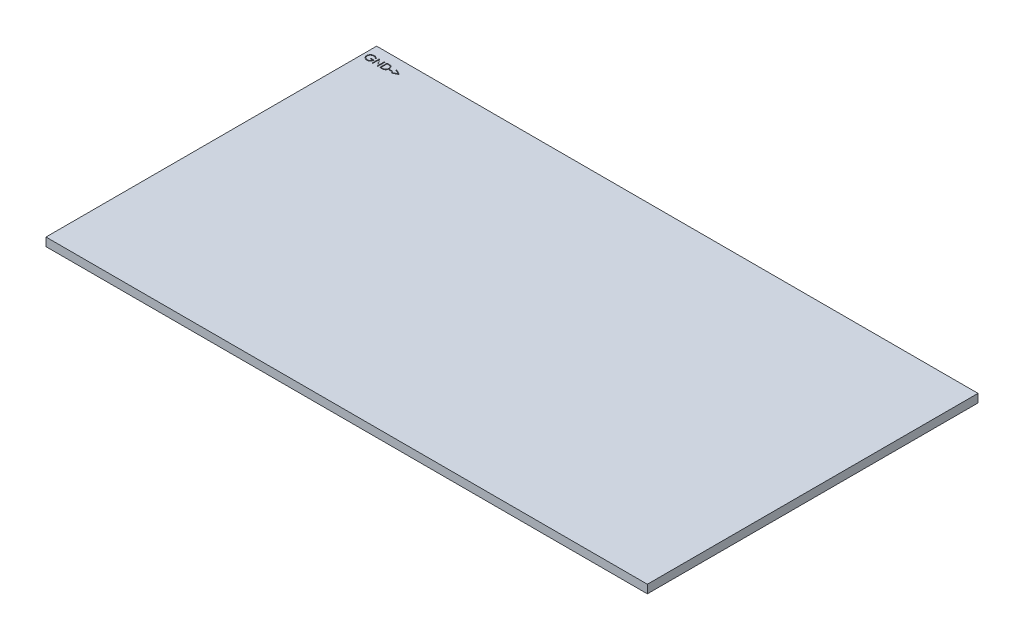
from build123d import *

# Parameters (mm, degrees)
SKETCH1_W           = 114.2
SKETCH1_H           = 62.784
BOSS_EXTRUDE1_DEPTH = 1.5875
SKETCH2_W           = 0.538461539
SKETCH2_H           = 0.143589744
CUT_EXTRUDE1_DEPTH  = 0.2
SKETCH5_W           = 0.538461539
SKETCH5_H           = 0.143589743
CUT_EXTRUDE2_DEPTH  = 0.2


with BuildPart() as part:
    # Sketch1 → Boss-Extrude1 (new body)
    with BuildSketch(Plane(origin=(0, 0, 0), x_dir=(1, 0, 0), z_dir=(0, 1, 0))):
        with Locations((57.1, 18.392)):
            Rectangle(SKETCH1_W, SKETCH1_H)
    extrude(amount=BOSS_EXTRUDE1_DEPTH)

    # Sketch2 → Cut-Extrude1 (cut)
    with BuildSketch(Plane(origin=(0, 1.5875, 0), x_dir=(1, 0, 0), z_dir=(0, 1, 0))):
        with BuildLine():
            Line((1.979573781, 47.737471022), (1.871881473, 47.635387688))
            add(Edge.make_bspline(
                [(1.871881473, 47.635387688), (1.852393918, 47.653720034), (1.813883499, 47.689947579), (1.751099402, 47.736951977), (1.685593949, 47.777218417), (1.61770895, 47.809980911), (1.549125528, 47.836122016), (1.480754018, 47.854733272), (1.413295737, 47.866602287), (1.36842885, 47.868021634), (1.346320576, 47.868721022)],
                knots=[0, 0, 0, 0, 8.0214e-05, 0.000158516, 0.0002348, 0.000310559, 0.000384315, 0.000454662, 0.000522898, 0.000589184, 0.000589184, 0.000589184, 0.000589184], degree=3))
            add(Edge.make_bspline(
                [(1.346320576, 47.868721022), (1.332754696, 47.868555579), (1.30565812, 47.868225124), (1.265409342, 47.864007438), (1.225582687, 47.857941492), (1.186253337, 47.849164741), (1.147344823, 47.838041117), (1.108992466, 47.824126932), (1.071124724, 47.807904834), (1.034098292, 47.789159845), (0.99820209, 47.768567906), (0.964299356, 47.74574849), (0.932173996, 47.721432974), (0.902429826, 47.695012582), (0.874895752, 47.666726636), (0.848916403, 47.637101313), (0.825405484, 47.605327226), (0.804169018, 47.571988976), (0.785224371, 47.5376721), (0.76850091, 47.502706904), (0.754462074, 47.467209362), (0.743354292, 47.431134931), (0.734190031, 47.394762695), (0.727742988, 47.357840807), (0.724108299, 47.320329733), (0.723479587, 47.29521083), (0.723163525, 47.282583201)],
                knots=[0, 0, 0, 0, 4.0681e-05, 8.1256e-05, 0.000121277, 0.000161491, 0.000202055, 0.000242597, 0.000283803, 0.000325569, 0.000367033, 0.000407869, 0.000448087, 0.00048782, 0.000527087, 0.000566449, 0.000605937, 0.000645536, 0.000684952, 0.000723463, 0.000761741, 0.00079935, 0.000836625, 0.000874202, 0.000911679, 0.000949566, 0.000949566, 0.000949566, 0.000949566], degree=3))
            add(Edge.make_bspline(
                [(0.723163525, 47.282583201), (0.723465812, 47.269674874), (0.724069561, 47.243893469), (0.727933689, 47.20541584), (0.735104985, 47.167509679), (0.744692069, 47.130050426), (0.756684395, 47.092973926), (0.771633461, 47.056440922), (0.789339702, 47.020452766), (0.809834322, 46.985333719), (0.832308804, 46.95112451), (0.857486036, 46.918900701), (0.88423027, 46.88823319), (0.913515829, 46.859802885), (0.944403646, 46.832849326), (0.977816557, 46.808115117), (1.013097541, 46.785123828), (1.050300426, 46.76416522), (1.089021539, 46.745441806), (1.12872424, 46.728792248), (1.169535366, 46.715080513), (1.211240442, 46.703905271), (1.253789751, 46.694745152), (1.297399272, 46.68885216), (1.341748355, 46.684575828), (1.371643808, 46.68426316), (1.386705191, 46.684105637)],
                knots=[0, 0, 0, 0, 3.8727e-05, 7.7349e-05, 0.000115853, 0.000154352, 0.000193286, 0.000232658, 0.000272668, 0.000313507, 0.000354576, 0.000395358, 0.000436093, 0.000476549, 0.000517706, 0.000558989, 0.000601149, 0.000643971, 0.000686993, 0.000730117, 0.000773042, 0.000816037, 0.0008596, 0.000903505, 0.00094799, 0.000993156, 0.000993156, 0.000993156, 0.000993156], degree=3))
            add(Edge.make_bspline(
                [(1.386705191, 46.684105637), (1.40485653, 46.684485068), (1.440499633, 46.685230141), (1.49289421, 46.691030257), (1.543215438, 46.700088974), (1.59132192, 46.713355333), (1.637269528, 46.730276803), (1.681226705, 46.750674958), (1.722847368, 46.775332181), (1.762256637, 46.803161728), (1.798559512, 46.834167661), (1.831301161, 46.867625443), (1.859959357, 46.90337267), (1.884961237, 46.941198796), (1.905644698, 46.981416918), (1.922621816, 47.023829943), (1.935635133, 47.068456948), (1.940977123, 47.0992936), (1.943676345, 47.114874868)],
                knots=[0, 0, 0, 0, 5.4442e-05, 0.000106907, 0.000157953, 0.000207688, 0.0002564, 0.000304703, 0.00035285, 0.000401328, 0.000449269, 0.000495875, 0.000541557, 0.000586516, 0.000631672, 0.00067698, 0.0007234, 0.000770811, 0.000770811, 0.000770811, 0.000770811], degree=3))
            Line((1.943676345, 47.114874868), (1.477009678, 47.114874868))
            Line((1.477009678, 47.114874868), (1.477009678, 47.258464611))
            Line((1.477009678, 47.258464611), (2.069317371, 47.258464611))
            add(Edge.make_bspline(
                [(2.069317371, 47.258464611), (2.068635031, 47.231701616), (2.06729957, 47.179321599), (2.057932004, 47.102933491), (2.042805399, 47.030784814), (2.022141274, 46.962799585), (1.995391162, 46.899074148), (1.962842151, 46.839543801), (1.923973302, 46.784593129), (1.880169126, 46.733773527), (1.831009142, 46.688441843), (1.777821694, 46.648599467), (1.720518907, 46.615038421), (1.659154984, 46.587734156), (1.593930811, 46.566424558), (1.524695459, 46.551315928), (1.451542819, 46.542263942), (1.401408148, 46.541107391), (1.375767691, 46.540515893)],
                knots=[0, 0, 0, 0, 8.0279e-05, 0.00015712, 0.000230495, 0.000301198, 0.000369951, 0.000437479, 0.000504314, 0.00057151, 0.00063839, 0.00070452, 0.000770512, 0.000837172, 0.000905638, 0.000975998, 0.001049464, 0.001126369, 0.001126369, 0.001126369, 0.001126369], degree=3))
            add(Edge.make_bspline(
                [(1.375767691, 46.540515893), (1.359963637, 46.540743542), (1.328792949, 46.541192538), (1.282756578, 46.544383477), (1.237989529, 46.549295708), (1.194498326, 46.556713757), (1.152122989, 46.565799619), (1.111075155, 46.577434306), (1.071198458, 46.590901786), (1.032431264, 46.606220055), (0.995125445, 46.623968718), (0.959114838, 46.643692574), (0.924200388, 46.665289918), (0.890619922, 46.689134256), (0.858198473, 46.71504724), (0.827145096, 46.743080808), (0.797285945, 46.773149256), (0.778581759, 46.79450086), (0.769157114, 46.805259483)],
                knots=[0, 0, 0, 0, 4.7409e-05, 9.3506e-05, 0.000138382, 0.000182459, 0.000225806, 0.000268336, 0.000310373, 0.000352036, 0.000393308, 0.000434223, 0.000475158, 0.000516399, 0.000557701, 0.000599601, 0.000641841, 0.000684741, 0.000684741, 0.000684741, 0.000684741], degree=3))
            add(Edge.make_bspline(
                [(0.769157114, 46.805259483), (0.755482742, 46.822327744), (0.728360977, 46.856180951), (0.693449714, 46.910420929), (0.663689153, 46.966581673), (0.639542024, 47.024819524), (0.620686789, 47.08508001), (0.607164288, 47.147286126), (0.599241373, 47.211517978), (0.598099958, 47.254984084), (0.597522499, 47.276974227)],
                knots=[0, 0, 0, 0, 6.5576e-05, 0.000130063, 0.000193165, 0.000256028, 0.000318917, 0.000382341, 0.000446764, 0.000512729, 0.000512729, 0.000512729, 0.000512729], degree=3))
            add(Edge.make_bspline(
                [(0.597522499, 47.276974227), (0.597735394, 47.293440728), (0.598158479, 47.326164451), (0.603288685, 47.374747374), (0.610649253, 47.422467651), (0.621468074, 47.469286273), (0.63510658, 47.51523451), (0.652127975, 47.560333695), (0.671945933, 47.604610444), (0.694980132, 47.647759991), (0.720613915, 47.689209756), (0.748434004, 47.728792878), (0.778835444, 47.765788504), (0.811321763, 47.800665163), (0.84628056, 47.832984702), (0.883384329, 47.863046346), (0.922661666, 47.89089042), (0.964236138, 47.916078354), (1.007487212, 47.938703803), (1.052311212, 47.958539487), (1.098694457, 47.974932813), (1.146289448, 47.988842325), (1.195456448, 47.999128381), (1.245838663, 48.00658788), (1.297698708, 48.01169212), (1.332753119, 48.012102622), (1.350527307, 48.012310765)],
                knots=[0, 0, 0, 0, 4.9379e-05, 9.813e-05, 0.000146404, 0.000194163, 0.000242165, 0.000290088, 0.000338668, 0.000387598, 0.000436708, 0.000484796, 0.000532627, 0.000580247, 0.000627676, 0.00067533, 0.000723418, 0.000771996, 0.000821044, 0.000869765, 0.000918909, 0.000968526, 0.001018415, 0.00106946, 0.001121283, 0.001174587, 0.001174587, 0.001174587, 0.001174587], degree=3))
            add(Edge.make_bspline(
                [(1.350527307, 48.012310765), (1.365022604, 48.012078969), (1.393765076, 48.011619343), (1.436535369, 48.008433484), (1.478644574, 48.003383931), (1.52015513, 47.996493217), (1.560925677, 47.98710774), (1.601072359, 47.975876427), (1.640653374, 47.962799698), (1.679544673, 47.947204159), (1.71800776, 47.929502709), (1.756256496, 47.90957734), (1.794160194, 47.887087338), (1.831784587, 47.861965924), (1.86936693, 47.834644557), (1.906312787, 47.804341827), (1.943513965, 47.772252725), (1.96743469, 47.749179852), (1.979573781, 47.737471022)],
                knots=[0, 0, 0, 0, 4.3484e-05, 8.6224e-05, 0.000128593, 0.000170687, 0.000212392, 0.000254036, 0.000295718, 0.00033738, 0.00037967, 0.000422695, 0.000466704, 0.000511818, 0.000558376, 0.00060603, 0.000655128, 0.000705715, 0.000705715, 0.000705715, 0.000705715], degree=3))
        make_face()
        Polygon((2.356496858, 46.576413329), (2.356496858, 47.976413329), (2.382859037, 47.976413329), (3.307778909, 46.874530317), (3.307778909, 47.976413329), (3.433419935, 47.976413329), (3.433419935, 46.576413329), (3.404814166, 46.576413329), (2.482137884, 47.675772304), (2.482137884, 46.576413329), align=None)
        with BuildLine():
            Line((3.792394294, 46.576413329), (3.792394294, 47.976413329))
            Line((3.792394294, 47.976413329), (4.075086602, 47.976413329))
            add(Edge.make_bspline(
                [(4.075086602, 47.976413329), (4.099674197, 47.976236301), (4.147177303, 47.975894284), (4.215822282, 47.973725728), (4.279335787, 47.969889541), (4.337508931, 47.964301731), (4.390501415, 47.957440517), (4.438164859, 47.948840356), (4.480745716, 47.938685088), (4.506933492, 47.930026907), (4.519317371, 47.92593256)],
                knots=[0, 0, 0, 0, 7.3763e-05, 0.000142509, 0.000206012, 0.000264615, 0.000317803, 0.000366266, 0.000409866, 0.000448981, 0.000448981, 0.000448981, 0.000448981], degree=3))
            add(Edge.make_bspline(
                [(4.519317371, 47.92593256), (4.535515266, 47.919760278), (4.567543743, 47.90755568), (4.613146592, 47.88453316), (4.656076738, 47.858447919), (4.696564396, 47.829265574), (4.733684726, 47.796159835), (4.768887885, 47.760537), (4.800733774, 47.721101664), (4.829897093, 47.678671669), (4.856191357, 47.633746848), (4.87904702, 47.586412805), (4.898028617, 47.536909921), (4.913785908, 47.485375862), (4.926204491, 47.431697311), (4.934677263, 47.375811765), (4.940265659, 47.317940089), (4.94082728, 47.278670303), (4.941112243, 47.25874506)],
                knots=[0, 0, 0, 0, 5.1974e-05, 0.000102769, 0.000152983, 0.000202572, 0.00025225, 0.000302028, 0.000352662, 0.000404082, 0.000456366, 0.000508672, 0.000561587, 0.000615258, 0.000670227, 0.00072671, 0.000784727, 0.000844486, 0.000844486, 0.000844486, 0.000844486], degree=3))
            add(Edge.make_bspline(
                [(4.941112243, 47.25874506), (4.940860656, 47.241440565), (4.940364877, 47.207340249), (4.935913151, 47.157083891), (4.929442623, 47.108318462), (4.919424944, 47.061276182), (4.907263938, 47.015544895), (4.891678278, 46.971611997), (4.873824079, 46.929074474), (4.853004128, 46.888507483), (4.830147574, 46.850074134), (4.805618877, 46.813843923), (4.779444198, 46.780333834), (4.751373945, 46.74944239), (4.721770859, 46.721216158), (4.690441126, 46.695419352), (4.657303906, 46.67255673), (4.622507617, 46.651729887), (4.585037165, 46.633561745), (4.544182819, 46.618189741), (4.499770348, 46.605451095), (4.451908765, 46.594822736), (4.400515374, 46.586391815), (4.345539787, 46.580741258), (4.287066472, 46.576920085), (4.246914765, 46.576585528), (4.226248461, 46.576413329)],
                knots=[0, 0, 0, 0, 5.1902e-05, 0.000102278, 0.000151261, 0.000199388, 0.000246466, 0.00029312, 0.000339115, 0.000384769, 0.000429788, 0.000473192, 0.000515942, 0.000557238, 0.000598299, 0.000638553, 0.000678852, 0.000718965, 0.000760106, 0.000803598, 0.000849749, 0.000898602, 0.000950609, 0.001005891, 0.001064339, 0.001126328, 0.001126328, 0.001126328, 0.001126328], degree=3))
            Line((4.226248461, 46.576413329), (3.792394294, 46.576413329))
        make_face()
        with BuildLine():
            Line((3.918035319, 46.720003073), (4.078732435, 46.720003073))
            add(Edge.make_bspline(
                [(4.078732435, 46.720003073), (4.101823783, 46.720102311), (4.146236903, 46.720293184), (4.210100101, 46.721968065), (4.26845186, 46.72470484), (4.321300464, 46.728534871), (4.368616074, 46.733602317), (4.410497573, 46.739252278), (4.446807677, 46.746291258), (4.468779452, 46.752671642), (4.478932755, 46.75562006)],
                knots=[0, 0, 0, 0, 6.9273e-05, 0.000133238, 0.000191638, 0.000244509, 0.000292173, 0.000334372, 0.000371278, 0.000402983, 0.000402983, 0.000402983, 0.000402983], degree=3))
            add(Edge.make_bspline(
                [(4.478932755, 46.75562006), (4.4917121, 46.760120683), (4.516965555, 46.769014433), (4.55331799, 46.785237497), (4.587220791, 46.804454325), (4.619264802, 46.825815235), (4.648995464, 46.850073635), (4.67676511, 46.876702031), (4.702517831, 46.905835941), (4.725987554, 46.937439206), (4.746990876, 46.971315124), (4.765179367, 47.007130657), (4.78111998, 47.044493381), (4.793631417, 47.083977045), (4.803437651, 47.125228668), (4.810383526, 47.168251154), (4.814709416, 47.213036466), (4.815213995, 47.243497316), (4.815471217, 47.259025509)],
                knots=[0, 0, 0, 0, 4.0637e-05, 8.0303e-05, 0.000119229, 0.000157421, 0.000195702, 0.000234182, 0.000272727, 0.000312214, 0.000352138, 0.000392149, 0.000432621, 0.000473862, 0.00051624, 0.000559718, 0.000604507, 0.000651083, 0.000651083, 0.000651083, 0.000651083], degree=3))
            add(Edge.make_bspline(
                [(4.815471217, 47.259025509), (4.815265902, 47.275398901), (4.814862559, 47.307564575), (4.809792835, 47.354760853), (4.802384213, 47.400153113), (4.791670738, 47.443744391), (4.778018387, 47.485619732), (4.76098053, 47.525547536), (4.741513882, 47.563949484), (4.718352547, 47.59993923), (4.69298631, 47.633976474), (4.664835158, 47.66515844), (4.634346343, 47.69355616), (4.601852403, 47.719611885), (4.566437563, 47.742277355), (4.528936087, 47.762552028), (4.488797819, 47.779758384), (4.46087274, 47.788909929), (4.446681153, 47.793560765)],
                knots=[0, 0, 0, 0, 4.9099e-05, 9.6455e-05, 0.000142237, 0.000186994, 0.000230983, 0.000274215, 0.000317112, 0.00035998, 0.00040244, 0.00044434, 0.000485809, 0.000527331, 0.000569104, 0.000611765, 0.000655108, 0.000699896, 0.000699896, 0.000699896, 0.000699896], degree=3))
            add(Edge.make_bspline(
                [(4.446681153, 47.793560765), (4.434940694, 47.796807336), (4.409977258, 47.803710437), (4.369241473, 47.811240586), (4.323395413, 47.817882386), (4.272235532, 47.823505602), (4.215820149, 47.82754053), (4.154105873, 47.830569056), (4.087066032, 47.832611709), (4.040593018, 47.832751192), (4.016472819, 47.832823586)],
                knots=[0, 0, 0, 0, 3.6528e-05, 7.7669e-05, 0.000124153, 0.000175502, 0.000232029, 0.000293804, 0.00036086, 0.000433218, 0.000433218, 0.000433218, 0.000433218], degree=3))
            Line((4.016472819, 47.832823586), (3.918035319, 47.832823586))
            Line((3.918035319, 47.832823586), (3.918035319, 46.720003073))
        make_face(mode=Mode.SUBTRACT)
        with Locations((5.371881474, 47.114874868)):
            Rectangle(SKETCH2_W, SKETCH2_H)
        Polygon((5.802650704, 46.892479034), (6.588468012, 47.26743897), (5.802650704, 47.642398906), (5.802650704, 47.778977432), (6.771881473, 47.316517496), (6.771881473, 47.218360445), (5.802650704, 46.755900509), align=None)
    extrude(amount=-CUT_EXTRUDE1_DEPTH, mode=Mode.SUBTRACT)

    # Sketch5 → Cut-Extrude2 (cut)
    with BuildSketch(Plane.XZ):
        with BuildLine():
            Line((99.651881869, -8.835487078), (99.759574177, -8.733403745))
            add(Edge.make_bspline(
                [(99.759574177, -8.733403745), (99.779175842, -8.751710916), (99.8178077, -8.787791526), (99.880489648, -8.835127659), (99.945978993, -8.875362021), (100.013743302, -8.908417616), (100.082475826, -8.934112893), (100.150804316, -8.952691933), (100.218249726, -8.964640525), (100.263025991, -8.966044058), (100.285135074, -8.966737078)],
                knots=[0, 0, 0, 0, 8.0422e-05, 0.0001585, 0.00023517, 0.000310677, 0.000384334, 0.000454952, 0.000522911, 0.000589197, 0.000589197, 0.000589197, 0.000589197], degree=3))
            add(Edge.make_bspline(
                [(100.285135074, -8.966737078), (100.298700878, -8.966571391), (100.325797302, -8.966240448), (100.366047213, -8.962026398), (100.405869614, -8.955946802), (100.445127178, -8.947240762), (100.483975989, -8.935933089), (100.522329623, -8.92228076), (100.560114058, -8.905846268), (100.597130519, -8.887109443), (100.633199685, -8.866655116), (100.667122928, -8.843842484), (100.699041711, -8.81937356), (100.72873032, -8.79292744), (100.756595423, -8.764944288), (100.782126935, -8.735026497), (100.805883193, -8.703616878), (100.826975631, -8.670265196), (100.846040083, -8.635919084), (100.862548275, -8.600852326), (100.876762784, -8.565312239), (100.888121044, -8.529278791), (100.897252651, -8.492774989), (100.903716121, -8.455857867), (100.907346476, -8.418345536), (100.90797577, -8.393226801), (100.908292125, -8.380599258)],
                knots=[0, 0, 0, 0, 4.0681e-05, 8.1256e-05, 0.000121277, 0.000161491, 0.000201786, 0.000242591, 0.00028354, 0.000325306, 0.000367013, 0.000407849, 0.000447844, 0.000487577, 0.000527041, 0.00056622, 0.000605483, 0.000645082, 0.000684498, 0.000723263, 0.00076128, 0.000799241, 0.000836515, 0.000874092, 0.00091157, 0.000949456, 0.000949456, 0.000949456, 0.000949456], degree=3))
            add(Edge.make_bspline(
                [(100.908292125, -8.380599258), (100.907986948, -8.367691717), (100.907377426, -8.341911882), (100.90355646, -8.303422511), (100.896226075, -8.265583241), (100.887272098, -8.228037099), (100.874597988, -8.191263311), (100.859864729, -8.154723339), (100.842099723, -8.118756777), (100.821642921, -8.083614328), (100.79903596, -8.049415274), (100.774176335, -8.016930015), (100.747017095, -7.986538199), (100.718057578, -7.957795483), (100.687033563, -7.930883377), (100.653644155, -7.906126234), (100.618356717, -7.883141243), (100.581155602, -7.862180909), (100.54243401, -7.843457962), (100.502731437, -7.826808278), (100.461920277, -7.813096576), (100.42021521, -7.801921326), (100.377665899, -7.792761209), (100.334056378, -7.786868217), (100.289707295, -7.782591884), (100.259811842, -7.782279216), (100.244750459, -7.782121694)],
                knots=[0, 0, 0, 0, 3.8727e-05, 7.7349e-05, 0.000115853, 0.000154284, 0.00019304, 0.000232411, 0.000272421, 0.00031326, 0.000354329, 0.000395333, 0.000435858, 0.000476511, 0.000517669, 0.000558951, 0.000601112, 0.000643933, 0.000686955, 0.00073008, 0.000773004, 0.000815999, 0.000859562, 0.000903467, 0.000947952, 0.000993118, 0.000993118, 0.000993118, 0.000993118], degree=3))
            add(Edge.make_bspline(
                [(100.244750459, -7.782121694), (100.226599046, -7.782500967), (100.190955798, -7.783245731), (100.138562271, -7.78904808), (100.088237219, -7.798098666), (100.040144498, -7.811394295), (99.99410949, -7.828223243), (99.950302281, -7.849034791), (99.908600792, -7.873609274), (99.869189672, -7.901451642), (99.832990611, -7.932465136), (99.800087708, -7.96566017), (99.77144513, -8.00130161), (99.746876082, -8.039381697), (99.725729206, -8.079339717), (99.708860621, -8.121860543), (99.695813584, -8.16646924), (99.6904762, -8.197308393), (99.687779305, -8.212890924)],
                knots=[0, 0, 0, 0, 5.4442e-05, 0.000106907, 0.000157953, 0.000207688, 0.0002564, 0.000304823, 0.000352969, 0.000401448, 0.000449388, 0.000495794, 0.000541476, 0.000586282, 0.000631567, 0.000676875, 0.000723295, 0.000770707, 0.000770707, 0.000770707, 0.000770707], degree=3))
            Line((99.687779305, -8.212890924), (100.154445972, -8.212890924))
            Line((100.154445972, -8.212890924), (100.154445972, -8.356480668))
            Line((100.154445972, -8.356480668), (99.562138279, -8.356480668))
            add(Edge.make_bspline(
                [(99.562138279, -8.356480668), (99.562820619, -8.329717672), (99.56415608, -8.277337656), (99.573523646, -8.200949547), (99.588650251, -8.12880087), (99.609314376, -8.060815641), (99.636064488, -7.997090204), (99.668613499, -7.937559858), (99.707482348, -7.882609185), (99.751286524, -7.831789584), (99.800446508, -7.786457899), (99.853633956, -7.746615524), (99.910936743, -7.713054478), (99.972300666, -7.685750213), (100.037524839, -7.664440615), (100.106760191, -7.649331984), (100.179912831, -7.640279999), (100.230047502, -7.639123447), (100.255687959, -7.63853195)],
                knots=[0, 0, 0, 0, 8.0279e-05, 0.00015712, 0.000230495, 0.000301198, 0.000369951, 0.000437479, 0.000504314, 0.00057151, 0.00063839, 0.00070452, 0.000770512, 0.000837172, 0.000905638, 0.000975998, 0.001049464, 0.001126369, 0.001126369, 0.001126369, 0.001126369], degree=3))
            add(Edge.make_bspline(
                [(100.255687959, -7.63853195), (100.271492013, -7.638759598), (100.302662701, -7.639208595), (100.348699072, -7.642399534), (100.393466121, -7.647311764), (100.436957324, -7.654729814), (100.479332661, -7.663815675), (100.520380495, -7.675450363), (100.560257192, -7.688917842), (100.599024386, -7.704236112), (100.636330205, -7.721984774), (100.672340812, -7.74170863), (100.707255262, -7.763305975), (100.740835728, -7.787150313), (100.773257177, -7.813063297), (100.804310554, -7.841096865), (100.834169705, -7.871165312), (100.852873891, -7.892516916), (100.862298536, -7.90327554)],
                knots=[0, 0, 0, 0, 4.7409e-05, 9.3506e-05, 0.000138382, 0.000182459, 0.000225806, 0.000268336, 0.000310373, 0.000352036, 0.000393308, 0.000434223, 0.000475158, 0.000516399, 0.000557701, 0.000599601, 0.000641841, 0.000684741, 0.000684741, 0.000684741, 0.000684741], degree=3))
            add(Edge.make_bspline(
                [(100.862298536, -7.90327554), (100.875972908, -7.920343801), (100.903094674, -7.954197008), (100.938005936, -8.008436986), (100.967766497, -8.06459773), (100.991913626, -8.122835581), (101.010768861, -8.183096066), (101.024291362, -8.245302183), (101.032214277, -8.309534035), (101.033355692, -8.353000141), (101.033933151, -8.374990283)],
                knots=[0, 0, 0, 0, 6.5576e-05, 0.000130063, 0.000193165, 0.000256028, 0.000318917, 0.000382341, 0.000446764, 0.000512729, 0.000512729, 0.000512729, 0.000512729], degree=3))
            add(Edge.make_bspline(
                [(101.033933151, -8.374990283), (101.033719679, -8.391456611), (101.033295448, -8.42417999), (101.028173727, -8.47276546), (101.020781417, -8.52047621), (101.01007394, -8.567356417), (100.995985583, -8.613197952), (100.979066009, -8.658353059), (100.959248376, -8.702641257), (100.936121924, -8.745670006), (100.910949049, -8.787424593), (100.882642549, -8.826590782), (100.852774898, -8.863925885), (100.819915174, -8.898372873), (100.785294704, -8.931032189), (100.748052355, -8.961043033), (100.708799142, -8.988911744), (100.667218109, -9.014092978), (100.623968813, -9.036720242), (100.579144337, -9.056555441), (100.532761221, -9.072948898), (100.485166195, -9.086858374), (100.435999204, -9.09714444), (100.385616987, -9.104603936), (100.333756942, -9.109708176), (100.298702531, -9.110118678), (100.280928343, -9.110326822)],
                knots=[0, 0, 0, 0, 4.9379e-05, 9.813e-05, 0.000146404, 0.000194163, 0.000242246, 0.00029017, 0.000338749, 0.000387679, 0.000436643, 0.000484893, 0.000532547, 0.000579963, 0.000627583, 0.000675237, 0.000723324, 0.000771903, 0.00082095, 0.000869672, 0.000918815, 0.000968432, 0.001018321, 0.001069367, 0.001121189, 0.001174493, 0.001174493, 0.001174493, 0.001174493], degree=3))
            add(Edge.make_bspline(
                [(100.280928343, -9.110326822), (100.26643294, -9.110095604), (100.237690258, -9.109637127), (100.194921517, -9.10644279), (100.152898044, -9.101435908), (100.111409034, -9.094434621), (100.070612458, -9.085173054), (100.030384717, -9.073885883), (99.990801895, -9.060817521), (99.951911081, -9.045219734), (99.913447862, -9.027518898), (99.875199162, -9.00759336), (99.837295454, -8.985103405), (99.799671064, -8.959981978), (99.76208872, -8.932660614), (99.725142863, -8.902357884), (99.687941685, -8.870268782), (99.66402096, -8.847195908), (99.651881869, -8.835487078)],
                knots=[0, 0, 0, 0, 4.3484e-05, 8.6224e-05, 0.000128593, 0.000170411, 0.000212389, 0.000254033, 0.000295715, 0.000337377, 0.000379667, 0.000422692, 0.000466701, 0.000511815, 0.000558373, 0.000606027, 0.000655125, 0.000705712, 0.000705712, 0.000705712, 0.000705712], degree=3))
        make_face()
        Polygon((99.274958792, -7.674429386), (99.274958792, -9.074429386), (99.248596613, -9.074429386), (98.323676741, -7.972546373), (98.323676741, -9.074429386), (98.198035715, -9.074429386), (98.198035715, -7.674429386), (98.226641484, -7.674429386), (99.149317766, -8.77378836), (99.149317766, -7.674429386), align=None)
        with BuildLine():
            Line((97.839061356, -7.674429386), (97.839061356, -9.074429386))
            Line((97.839061356, -9.074429386), (97.556369049, -9.074429386))
            add(Edge.make_bspline(
                [(97.556369049, -9.074429386), (97.531781402, -9.07425284), (97.484278197, -9.073911755), (97.415633903, -9.071736737), (97.352210986, -9.067927977), (97.294045464, -9.062273052), (97.24104389, -9.055485557), (97.19329115, -9.046853559), (97.150709859, -9.036701744), (97.124522134, -9.028043157), (97.112138279, -9.023948617)],
                knots=[0, 0, 0, 0, 7.3763e-05, 0.000142509, 0.000206012, 0.000264335, 0.000317802, 0.000366264, 0.000409865, 0.00044898, 0.00044898, 0.00044898, 0.00044898], degree=3))
            add(Edge.make_bspline(
                [(97.112138279, -9.023948617), (97.095938935, -9.01777825), (97.063907594, -9.005577439), (97.018325773, -8.982527115), (96.975270052, -8.95651688), (96.935080401, -8.92695041), (96.897668262, -8.894205528), (96.862562912, -8.858547168), (96.830770578, -8.819023372), (96.801194735, -8.776860547), (96.775308199, -8.731675004), (96.752481249, -8.684371804), (96.732990499, -8.635042727), (96.717782479, -8.583327844), (96.705218026, -8.529723854), (96.696787586, -8.47382491), (96.691187584, -8.415956907), (96.69062756, -8.376686616), (96.690343407, -8.356761117)],
                knots=[0, 0, 0, 0, 5.1974e-05, 0.000102769, 0.000152983, 0.000202737, 0.00025223, 0.000302009, 0.000352642, 0.000404222, 0.000456366, 0.000508672, 0.000561688, 0.000615278, 0.000670247, 0.000726729, 0.000784747, 0.000844506, 0.000844506, 0.000844506, 0.000844506], degree=3))
            add(Edge.make_bspline(
                [(96.690343407, -8.356761117), (96.690595164, -8.33945668), (96.691091277, -8.30535648), (96.695540574, -8.255099282), (96.70201998, -8.206336922), (96.712005463, -8.159283512), (96.724275393, -8.113622254), (96.739419615, -8.069569347), (96.757369363, -8.02709485), (96.778185973, -7.986536127), (96.800979311, -7.947991801), (96.825816395, -7.912072583), (96.851846819, -7.878382447), (96.880019959, -7.847682491), (96.909403032, -7.81901671), (96.940995396, -7.793656719), (96.973807857, -7.770425187), (97.008826197, -7.750027616), (97.046337728, -7.73188337), (97.087322305, -7.716560446), (97.131630345, -7.703373928), (97.179555443, -7.692867812), (97.230937763, -7.684399351), (97.285916592, -7.67875979), (97.344388979, -7.674935464), (97.384540817, -7.674601354), (97.40520719, -7.674429386)],
                knots=[0, 0, 0, 0, 5.1902e-05, 0.000102278, 0.000151261, 0.000199388, 0.000246466, 0.000293028, 0.000339023, 0.000384677, 0.000429696, 0.000473259, 0.000515615, 0.000557307, 0.000598166, 0.000638637, 0.000678706, 0.000718676, 0.00076007, 0.000803562, 0.000849792, 0.000898644, 0.000950652, 0.001005934, 0.001064381, 0.001126371, 0.001126371, 0.001126371, 0.001126371], degree=3))
            Line((97.40520719, -7.674429386), (97.839061356, -7.674429386))
        make_face()
        with BuildLine():
            Line((97.713420331, -7.818019129), (97.552723215, -7.818019129))
            add(Edge.make_bspline(
                [(97.552723215, -7.818019129), (97.529631867, -7.818118368), (97.485218748, -7.81830924), (97.421355549, -7.819984121), (97.36300379, -7.822720896), (97.310155186, -7.826550927), (97.262839577, -7.831618374), (97.220958077, -7.837268335), (97.184647973, -7.844307315), (97.162676198, -7.850687699), (97.152522895, -7.853636117)],
                knots=[0, 0, 0, 0, 6.9273e-05, 0.000133238, 0.000191638, 0.000244509, 0.000292173, 0.000334372, 0.000371278, 0.000402983, 0.000402983, 0.000402983, 0.000402983], degree=3))
            add(Edge.make_bspline(
                [(97.152522895, -7.853636117), (97.139743278, -7.858136404), (97.114489286, -7.867029488), (97.078140779, -7.883257415), (97.04422349, -7.902456304), (97.012171983, -7.923923343), (96.982192242, -7.947990006), (96.954423101, -7.974732828), (96.928645218, -8.003842203), (96.905271322, -8.035416216), (96.884131488, -8.069104538), (96.86586674, -8.104869642), (96.850469765, -8.142510828), (96.83783757, -8.181897134), (96.82798879, -8.223052004), (96.821054861, -8.266078715), (96.816757987, -8.310960274), (96.816245096, -8.341513656), (96.815984433, -8.357041565)],
                knots=[0, 0, 0, 0, 4.0637e-05, 8.0303e-05, 0.000119229, 0.000157421, 0.00019592, 0.0002344, 0.000272945, 0.000312432, 0.000352119, 0.000392129, 0.000432752, 0.000473993, 0.000516099, 0.000559577, 0.000604645, 0.000651221, 0.000651221, 0.000651221, 0.000651221], degree=3))
            add(Edge.make_bspline(
                [(96.815984433, -8.357041565), (96.816189967, -8.373414859), (96.81659374, -8.405580341), (96.821660362, -8.452778008), (96.829080224, -8.498165233), (96.839753118, -8.541774691), (96.853541577, -8.583549646), (96.870040585, -8.623726107), (96.890072971, -8.661787044), (96.912751749, -8.698054816), (96.938212831, -8.731980172), (96.966343273, -8.763165658), (96.996846456, -8.791669364), (97.0295818, -8.817536675), (97.065007001, -8.840307574), (97.102522595, -8.860564211), (97.142657039, -8.877775454), (97.170582643, -8.886926327), (97.184774497, -8.891576822)],
                knots=[0, 0, 0, 0, 4.9099e-05, 9.6455e-05, 0.000142237, 0.000186994, 0.000230983, 0.000274107, 0.000317133, 0.000359851, 0.000402311, 0.000444211, 0.00048568, 0.000527422, 0.000569195, 0.000611856, 0.000655199, 0.000699987, 0.000699987, 0.000699987, 0.000699987], degree=3))
            add(Edge.make_bspline(
                [(97.184774497, -8.891576822), (97.196514956, -8.894823393), (97.221478392, -8.901726494), (97.262214177, -8.909256643), (97.308060237, -8.915898443), (97.359220118, -8.921521658), (97.415635501, -8.925556587), (97.477349777, -8.928585113), (97.544389618, -8.930627766), (97.590862632, -8.930767249), (97.614982831, -8.930839642)],
                knots=[0, 0, 0, 0, 3.6528e-05, 7.7669e-05, 0.000124153, 0.000175502, 0.000232029, 0.000293804, 0.00036086, 0.000433218, 0.000433218, 0.000433218, 0.000433218], degree=3))
            Line((97.614982831, -8.930839642), (97.713420331, -8.930839642))
            Line((97.713420331, -8.930839642), (97.713420331, -7.818019129))
        make_face(mode=Mode.SUBTRACT)
        with Locations((96.259574177, -8.212890924)):
            Rectangle(SKETCH5_W, SKETCH5_H)
        Polygon((95.828804946, -7.990495091), (95.042987638, -8.365455027), (95.828804946, -8.740414963), (95.828804946, -8.876993488), (94.859574177, -8.414533553), (94.859574177, -8.316376501), (95.828804946, -7.853916565), align=None)
    extrude(amount=-CUT_EXTRUDE2_DEPTH, mode=Mode.SUBTRACT)


solid = part.part
